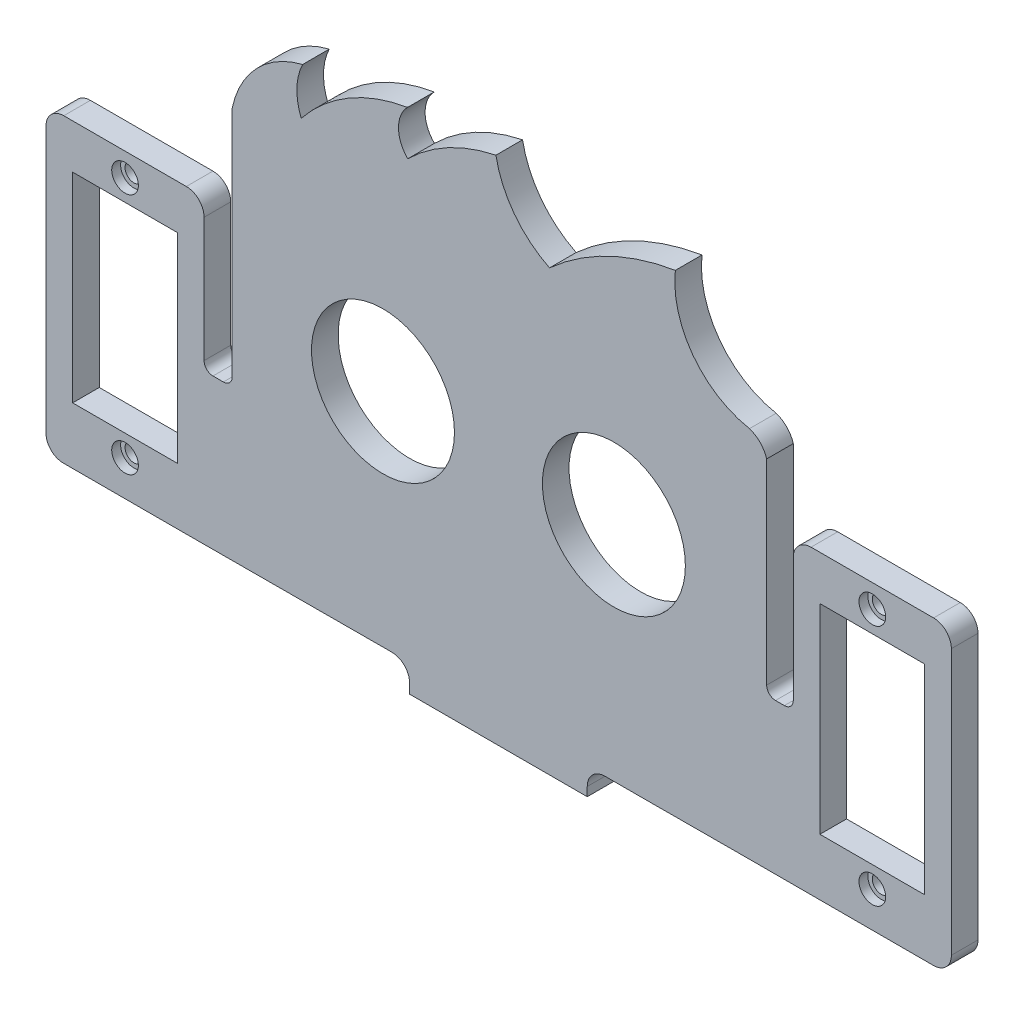
from build123d import *

# Parameters (mm, degrees)
MODEL_R                 = 8.05
MODEL_R_2               = 1
MODEL_W                 = 11.8
MODEL_H                 = 22.5
SALIENTE_EXTRUIR1_DEPTH = 3
CROQUIS1_W              = 19.999999999
CROQUIS1_H              = 3
SALIENTE_EXTRUIR2_DEPTH = 8
CROQUIS2_R              = 1.5
CORTAR_EXTRUIR1_DEPTH   = 3
REDONDEO2_R             = 2
CROQUIS3_R              = 1.5
CORTAR_EXTRUIR2_DEPTH   = 1
CROQUIS4_R              = 2.25
CORTAR_EXTRUIR3_DEPTH   = 1


with BuildPart() as part:
    # Model → Saliente-Extruir1 (new body)
    with BuildSketch(Plane.XY):
        with BuildLine():
            Line((28.555278924, -36.098945331), (29.722974743, -36.098945331))
            ThreePointArc((29.722974743, -36.098945331), (30.430081524, -35.806052112), (30.722974743, -35.098945331))
            Line((30.722974743, -35.098945331), (30.722974743, -8.898603015))
            ThreePointArc((30.722974743, -8.898603015), (33.490026108, -3.637946704), (38.646410135, -0.681127156))
            ThreePointArc((38.646410135, -0.681127156), (38.00468524, -3.326803395), (38.499385848, -6.00386987))
            ThreePointArc((38.499385848, -6.00386987), (43.828182769, -1.365184752), (50.466982875, 1.051385009))
            ThreePointArc((50.466982875, 1.051385009), (49.442986911, -1.453363029), (50.490036744, -3.948561843))
            ThreePointArc((50.490036744, -3.948561843), (55.067544133, -0.573430734), (60.41559095, 1.361376528))
            ThreePointArc((60.41559095, 1.361376528), (62.493005652, -3.33729886), (66.452413363, -6.610873791))
            ThreePointArc((66.452413363, -6.610873791), (73.044296854, -2.168793623), (80.620547187, 0.236499516))
            ThreePointArc((80.620547187, 0.236499516), (82.584961535, -7.032813492), (88.968686823, -11.026544426))
            ThreePointArc((88.968686823, -11.026544426), (90.178347555, -11.787115236), (90.898959582, -13.020997464))
            Line((90.898959582, -13.020997464), (90.898959582, -35.070997464))
            ThreePointArc((90.898959582, -35.070997464), (91.191852801, -35.778104245), (91.898959582, -36.070997464))
            Line((91.898959582, -36.070997464), (92.898959582, -36.070997464))
            ThreePointArc((92.898959582, -36.070997464), (93.606066364, -35.778104245), (93.898959582, -35.070997464))
            Line((93.898959582, -35.070997464), (93.898959582, -21.120997464))
            ThreePointArc((93.898959582, -21.120997464), (94.48474602, -19.706783901), (95.898959582, -19.120997464))
            Line((95.898959582, -19.120997464), (109.698959582, -19.120997464))
            ThreePointArc((109.698959582, -19.120997464), (111.113173145, -19.706783901), (111.698959582, -21.120997464))
            Line((111.698959582, -21.120997464), (111.698959582, -51.020997464))
            ThreePointArc((111.698959582, -51.020997464), (111.113173145, -52.435211026), (109.698959582, -53.020997464))
            Line((109.698959582, -53.020997464), (88.898959583, -53.020997464))
            Line((88.898959583, -53.020997464), (76.898959583, -53.057975795))
            Line((76.898959583, -53.057975795), (72.698959583, -53.057975795))
            ThreePointArc((72.698959583, -53.057975795), (71.28474602, -53.643762233), (70.698959583, -55.057975795))
            Line((70.698959583, -55.057975795), (70.698959583, -56.057975795))
            Line((70.698959583, -56.057975795), (50.698959583, -56.057975795))
            Line((50.698959583, -56.057975795), (50.698959583, -54.961647582))
            ThreePointArc((50.698959583, -54.961647582), (50.111367037, -53.545630215), (48.6938544, -52.961654097))
            Line((48.6938544, -52.961654097), (25.611598266, -53.020573857))
            Line((25.611598266, -53.020573857), (11.698959583, -53.020573857))
            ThreePointArc((11.698959583, -53.020573857), (10.324569809, -52.451282972), (9.755278924, -51.076893199))
            Line((9.755278924, -51.076893199), (9.755278924, -21.120997464))
            ThreePointArc((9.755278924, -21.120997464), (10.341065362, -19.706783901), (11.755278924, -19.120997464))
            Line((11.755278924, -19.120997464), (25.555278924, -19.120997464))
            ThreePointArc((25.555278924, -19.120997464), (26.969492487, -19.706783901), (27.555278924, -21.120997464))
            Line((27.555278924, -21.120997464), (27.555278924, -35.098945331))
            ThreePointArc((27.555278924, -35.098945331), (27.848172143, -35.806052112), (28.555278924, -36.098945331))
        make_face()
        with Locations((73.698959582, -28.020997464)):
            Circle(MODEL_R, mode=Mode.SUBTRACT)
        with Locations((47.698959583, -28.020997464)):
            Circle(MODEL_R, mode=Mode.SUBTRACT)
        with Locations((102.798959583, -21.720997464)):
            Circle(MODEL_R_2, mode=Mode.SUBTRACT)
        with Locations((102.798959583, -49.020997464)):
            Circle(MODEL_R_2, mode=Mode.SUBTRACT)
        with Locations((18.655278924, -49.020997464)):
            Circle(MODEL_R_2, mode=Mode.SUBTRACT)
        with Locations((18.655278924, -21.720997464)):
            Circle(MODEL_R_2, mode=Mode.SUBTRACT)
        with Locations((102.798959582, -35.370997464)):
            Rectangle(MODEL_W, MODEL_H, mode=Mode.SUBTRACT)
        with Locations((18.655278924, -35.370997464)):
            Rectangle(MODEL_W, MODEL_H, mode=Mode.SUBTRACT)
    extrude(amount=SALIENTE_EXTRUIR1_DEPTH)

    # Croquis1 → Saliente-Extruir2 (add)
    with BuildSketch(Plane(origin=(0, 0, 0), x_dir=(-1, 0, 0), z_dir=(0, 0, -1))):
        with Locations((-60.698959583, -54.557975795)):
            Rectangle(CROQUIS1_W, CROQUIS1_H)
    extrude(amount=SALIENTE_EXTRUIR2_DEPTH)

    # Croquis2 → Cortar-Extruir1 (cut)
    with BuildSketch(Plane(origin=(0, -53.057975795, 0), x_dir=(1, 0, 0), z_dir=(0, 1, 0))):
        with Locations((66.698959583, 3.5)):
            Circle(CROQUIS2_R)
        with Locations((54.698959583, 3.5)):
            Circle(CROQUIS2_R)
    extrude(amount=-CORTAR_EXTRUIR1_DEPTH, mode=Mode.SUBTRACT)

    # Redondeo2
    redondeo2_edges = [part.edges().sort_by_distance(p)[0] for p in [
        (50.698959583, -54.557975795, -8),
        (70.698959583, -54.557975795, -8),
    ]]
    fillet(redondeo2_edges, radius=REDONDEO2_R)

    # Croquis3 → Cortar-Extruir2 (cut)
    with BuildSketch(Plane.XY.offset(3)):
        with Locations((18.655278924, -21.720997464)):
            Circle(CROQUIS3_R)
        with Locations((18.655278924, -49.020997464)):
            Circle(CROQUIS3_R)
        with Locations((102.798959583, -49.020997464)):
            Circle(CROQUIS3_R)
        with Locations((102.798959583, -21.720997464)):
            Circle(CROQUIS3_R)
    extrude(amount=-CORTAR_EXTRUIR2_DEPTH, mode=Mode.SUBTRACT)

    # Croquis4 → Cortar-Extruir3 (cut)
    with BuildSketch(Plane(origin=(0, -53.057975795, 0), x_dir=(1, 0, 0), z_dir=(0, 1, 0))):
        with Locations((54.698959583, 3.5)):
            Circle(CROQUIS4_R)
        with Locations((66.698959583, 3.5)):
            Circle(CROQUIS4_R)
    extrude(amount=-CORTAR_EXTRUIR3_DEPTH, mode=Mode.SUBTRACT)


solid = part.part
